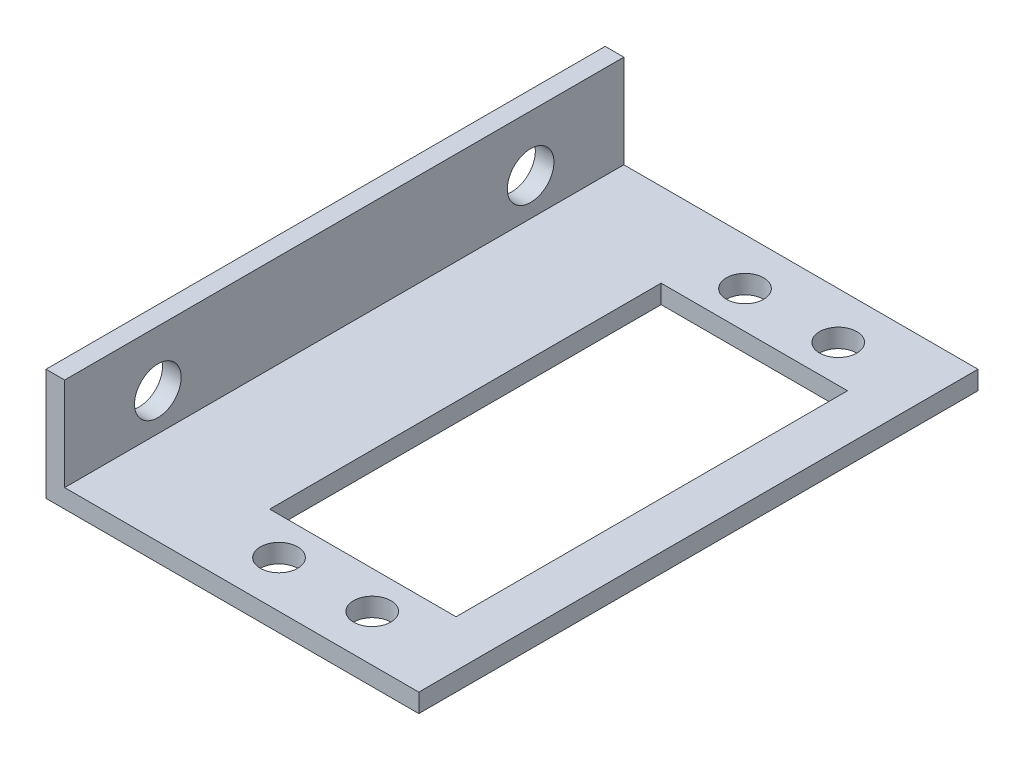
from build123d import *

# Parameters (mm, degrees)
SALIENTE_EXTRUIR1_DEPTH = 60
CROQUIS3_R              = 2.5
CORTAR_EXTRUIR1_DEPTH   = 60
CROQUIS4_R              = 2
CROQUIS4_W              = 20
CROQUIS4_H              = 42
CORTAR_EXTRUIR2_DEPTH   = 60


with BuildPart() as part:
    # Croquis2 → Saliente-Extruir1 (new body)
    with BuildSketch(Plane.XY):
        Polygon((22.222055452, 0), (-17.777944548, 0), (-17.777944548, 12), (-15.777944548, 12), (-15.777944548, 2), (22.222055452, 2), align=None)
    extrude(amount=SALIENTE_EXTRUIR1_DEPTH)

    # Croquis3 → Cortar-Extruir1 (cut)
    with BuildSketch(Plane.ZY.offset(17.777944548)):
        with Locations((10, 6)):
            Circle(CROQUIS3_R)
        with Locations((50, 6)):
            Circle(CROQUIS3_R)
    extrude(amount=-CORTAR_EXTRUIR1_DEPTH, mode=Mode.SUBTRACT)

    # Croquis4 → Cortar-Extruir2 (cut)
    with BuildSketch(Plane.XZ):
        with Locations((2.222055452, 55)):
            Circle(CROQUIS4_R)
        with Locations((12.222055452, 55)):
            Circle(CROQUIS4_R)
        with Locations((2.222055452, 5)):
            Circle(CROQUIS4_R)
        with Locations((12.222055452, 5)):
            Circle(CROQUIS4_R)
        with Locations((7.222055452, 30)):
            Rectangle(CROQUIS4_W, CROQUIS4_H)
    extrude(amount=-CORTAR_EXTRUIR2_DEPTH, mode=Mode.SUBTRACT)


solid = part.part
